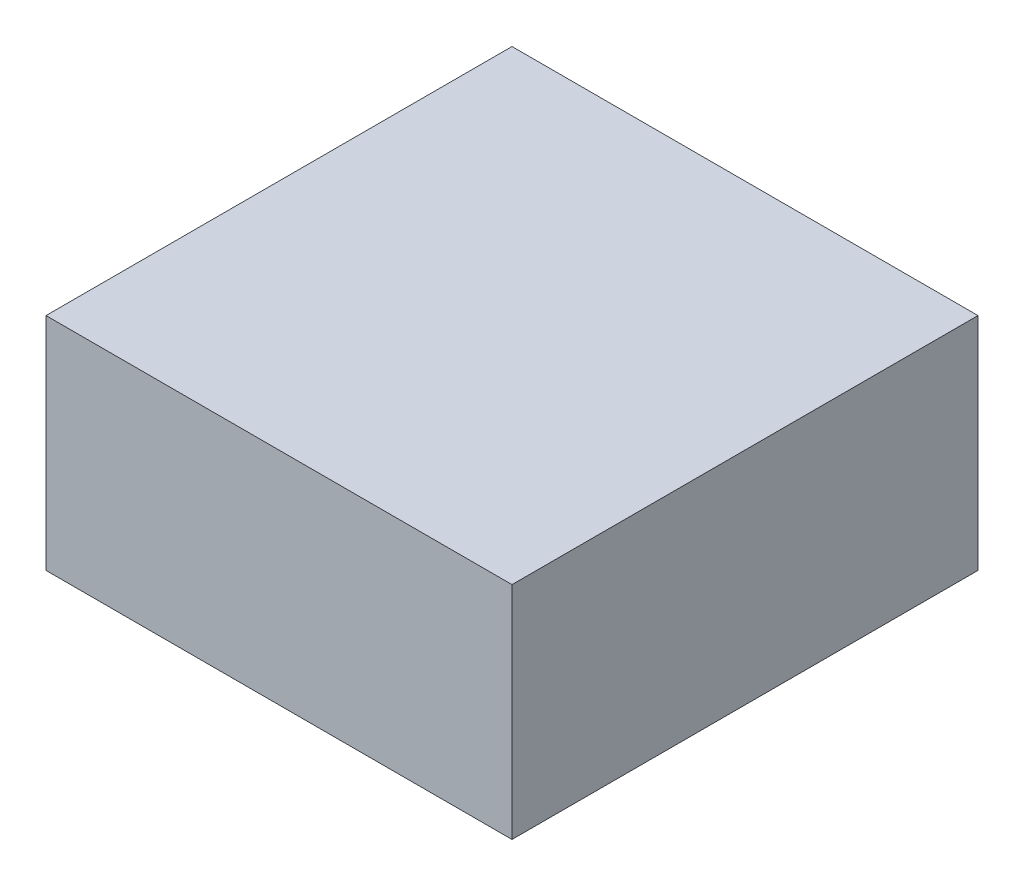
from build123d import *

# Parameters (mm, degrees)
SKETCH1_W           = 38
SKETCH1_H           = 38
BOSS_EXTRUDE1_DEPTH = 18


with BuildPart() as part:
    # Sketch1 → Boss-Extrude1 (new body)
    with BuildSketch(Plane(origin=(0, 0, 0), x_dir=(1, 0, 0), z_dir=(0, 1, 0))):
        with Locations((19, 19)):
            Rectangle(SKETCH1_W, SKETCH1_H)
    extrude(amount=BOSS_EXTRUDE1_DEPTH)


solid = part.part
